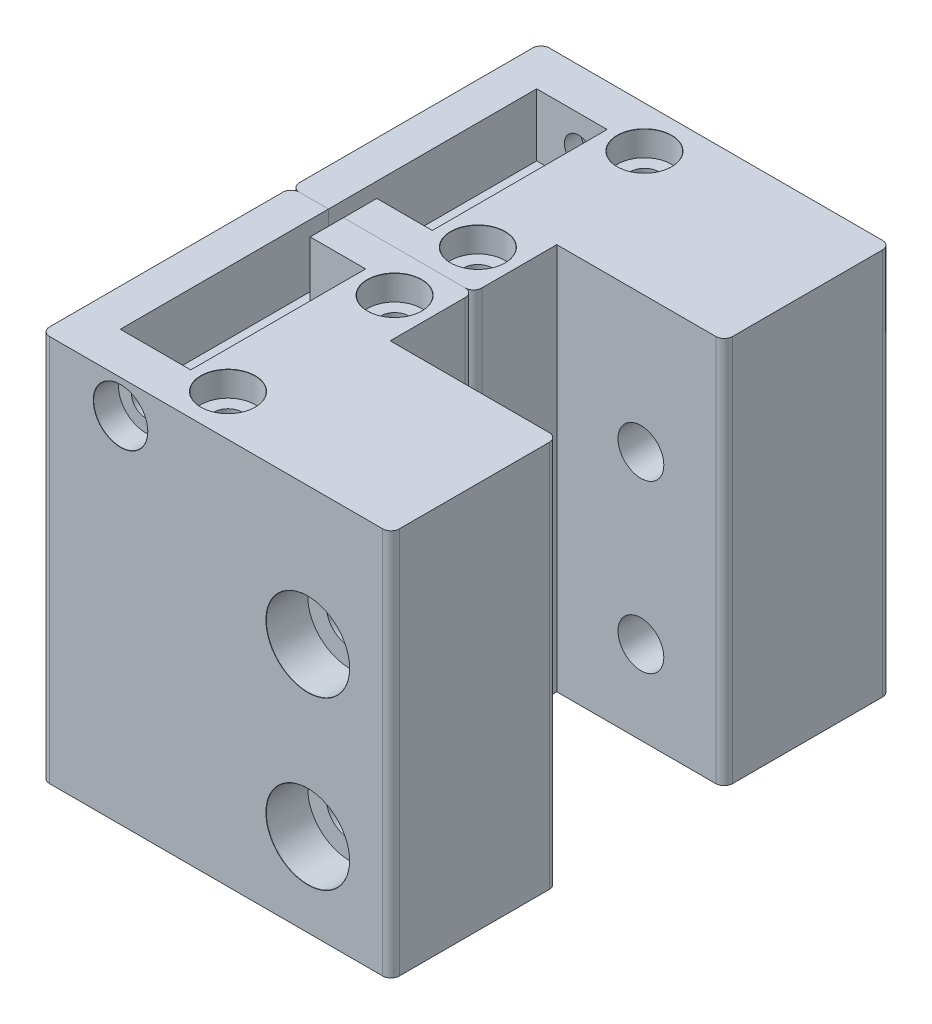
from build123d import *

# Parameters (mm, degrees)
SKETCH1_W                     = 42
SKETCH1_H                     = 20
BOSS_EXTRUDE1_DEPTH           = 40
CBORE_FOR_M5_SHCS1_AT_2_COUNT = 2
CBORE_FOR_M5_SHCS1_AT_2_PITCH = 20
SKETCH5_W                     = 42
SKETCH5_H                     = 20
BOSS_EXTRUDE2_DEPTH           = 6.5
SKETCH12_W                    = 21.9
SKETCH12_H                    = 10
BOSS_EXTRUDE3_DEPTH           = 46.5
CUT_EXTRUDE1_DEPTH            = 7.5
FILLET1_R                     = 1
CBORE_FOR_M3_SHCS2_AT_2_COUNT = 2
CBORE_FOR_M3_SHCS2_AT_2_PITCH = 20
CUT_EXTRUDE2_DEPTH            = 8


with BuildPart() as part:
    # Sketch1 → Boss-Extrude1 (new body)
    with BuildSketch(Plane(origin=(0, 0, 0), x_dir=(1, 0, 0), z_dir=(0, 1, 0))):
        Rectangle(SKETCH1_W, SKETCH1_H)
    extrude(amount=BOSS_EXTRUDE1_DEPTH)

    # Sketch4 → CBORE for M5 SHCS1 (revolve, cut)
    with BuildSketch(Plane(origin=(11, 30, 10), x_dir=(0, -1, 0), z_dir=(1, 0, 0))):
        Polygon((0, 0), (0, 20), (2.75, 20), (2.75, 5), (5, 5), (5, 0.020977491), (5.025, 0), align=None)
    cbore_for_m5_shcs1 = revolve(axis=Axis((11, 30, 16.35), (0, 0, -1)), mode=Mode.SUBTRACT)

    # CBORE for M5 SHCS1 at 2: CBORE for M5 SHCS1 ×2
    with Locations(*[(0, -i * CBORE_FOR_M5_SHCS1_AT_2_PITCH, 0) for i in range(1, CBORE_FOR_M5_SHCS1_AT_2_COUNT)]):
        add(cbore_for_m5_shcs1, mode=Mode.SUBTRACT)

    # Sketch5 → Boss-Extrude2 (add)
    with BuildSketch(Plane(origin=(0, 40, 0), x_dir=(1, 0, 0), z_dir=(0, 1, 0))):
        Rectangle(SKETCH5_W, SKETCH5_H)
    extrude(amount=BOSS_EXTRUDE2_DEPTH)

    # Sketch12 → Boss-Extrude3 (add)
    with BuildSketch(Plane(origin=(0, 46.5, 0), x_dir=(1, 0, 0), z_dir=(0, 1, 0))):
        with Locations((-10.05, 15)):
            Rectangle(SKETCH12_W, SKETCH12_H)
    extrude(amount=-BOSS_EXTRUDE3_DEPTH)

    # Sketch6 → Cut-Extrude1 (cut)
    with BuildSketch(Plane(origin=(0, 46.5, 0), x_dir=(1, 0, 0), z_dir=(0, 1, 0))):
        Polygon((-16.51, 20), (-16.51, -5), (-8.05, -5), (-8.05, 16), (-14.71, 16), (-14.71, 20), align=None)
    extrude(amount=-CUT_EXTRUDE1_DEPTH, mode=Mode.SUBTRACT)

    # Fillet1
    fillet1_edges = [part.edges().sort_by_distance(p)[0] for p in [
        (0.9, 23.25, -20),
        (-21, 23.25, -20),
        (21, 23.25, -10),
        (21, 23.25, 10),
        (-21, 23.25, 10),
    ]]
    fillet(fillet1_edges, radius=FILLET1_R)

    # Sketch11 → CBORE for M3 SHCS1 (revolve, cut)
    with BuildSketch(Plane(origin=(-11.48, 42.5, 10), x_dir=(0, -1, 0), z_dir=(1, 0, 0))):
        Polygon((0, 0), (0, 6.021463052), (1.7, 5), (1.7, 3), (3.25, 3), (3.25, 0.020977491), (3.275, 0), align=None)
    revolve(axis=Axis((-11.48, 42.5, 16.35), (0, 0, -1)), mode=Mode.SUBTRACT)

    # Sketch16 → CBORE for M3 SHCS2 (revolve, cut)
    with BuildSketch(Plane(origin=(-3.575, 46.5, -15), x_dir=(0, 0, 1), z_dir=(1, 0, 0))):
        Polygon((0, 0), (0, 46.5), (1.7, 46.5), (1.7, 3), (3.25, 3), (3.25, 0.020977491), (3.275, 0), align=None)
    cbore_for_m3_shcs2 = revolve(axis=Axis((-3.575, 52.85, -15), (0, -1, 0)), mode=Mode.SUBTRACT)

    # CBORE for M3 SHCS2 at 2: CBORE for M3 SHCS2 ×2
    with Locations(*[(0, 0, i * CBORE_FOR_M3_SHCS2_AT_2_PITCH) for i in range(1, CBORE_FOR_M3_SHCS2_AT_2_COUNT)]):
        add(cbore_for_m3_shcs2, mode=Mode.SUBTRACT)

    # Sketch18 → Cut-Extrude2 (cut)
    with BuildSketch(Plane.XZ):
        Polygon((-0.475, 5), (-2.025, 7.684678752), (-5.125, 7.684678752), (-6.675, 5), (-5.125, 2.315321248), (-2.025, 2.315321248), align=None)
        Polygon((-0.475, -15), (-2.025, -12.315321248), (-5.125, -12.315321248), (-6.675, -15), (-5.125, -17.684678752), (-2.025, -17.684678752), align=None)
    extrude(amount=-CUT_EXTRUDE2_DEPTH, mode=Mode.SUBTRACT)


with BuildPart() as body_2:
    # Mirror1: mirrored copy
    add(part.part.mirror(Plane(origin=(-21, -24.075090862, -20), x_dir=(1, 0, 0), z_dir=(0, 0, -1))))


solid = Compound([part.part, body_2.part])
